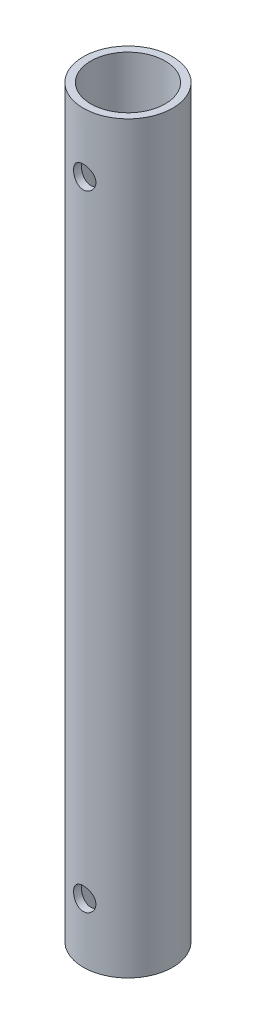
from build123d import *

# Parameters (mm, degrees)
SKETCH1_R               = 6
SKETCH1_R_2             = 5
EXTRUDE_THIN1_DEPTH     = 100
SKETCH2_R               = 1.5
CUT_EXTRUDE2_DEPTH      = 7
CUT_EXTRUDE2_DEPTH_BACK = 7
SKETCH3_R               = 1.5
CUT_EXTRUDE3_DEPTH      = 7.000000127
CUT_EXTRUDE3_DEPTH_BACK = 7.000000127


with BuildPart() as part:
    # Sketch1 → Extrude-Thin1 (new body)
    with BuildSketch(Plane(origin=(0, 0, 0), x_dir=(1, 0, 0), z_dir=(0, 1, 0))):
        Circle(SKETCH1_R)
        Circle(SKETCH1_R_2, mode=Mode.SUBTRACT)
    extrude(amount=EXTRUDE_THIN1_DEPTH)

    # Sketch2 → Cut-Extrude2 (cut, two sides)
    with BuildSketch(Plane.XY) as cut_extrude2_sk:
        with Locations((0, 8)):
            Circle(SKETCH2_R)
    extrude(amount=CUT_EXTRUDE2_DEPTH, mode=Mode.SUBTRACT)
    extrude(cut_extrude2_sk.sketch, amount=-CUT_EXTRUDE2_DEPTH_BACK, mode=Mode.SUBTRACT)

    # Sketch3 → Cut-Extrude3 (cut, two sides)
    with BuildSketch(Plane.XY) as cut_extrude3_sk:
        with Locations((0, 92)):
            Circle(SKETCH3_R)
    extrude(amount=CUT_EXTRUDE3_DEPTH, mode=Mode.SUBTRACT)
    extrude(cut_extrude3_sk.sketch, amount=-CUT_EXTRUDE3_DEPTH_BACK, mode=Mode.SUBTRACT)


solid = part.part
